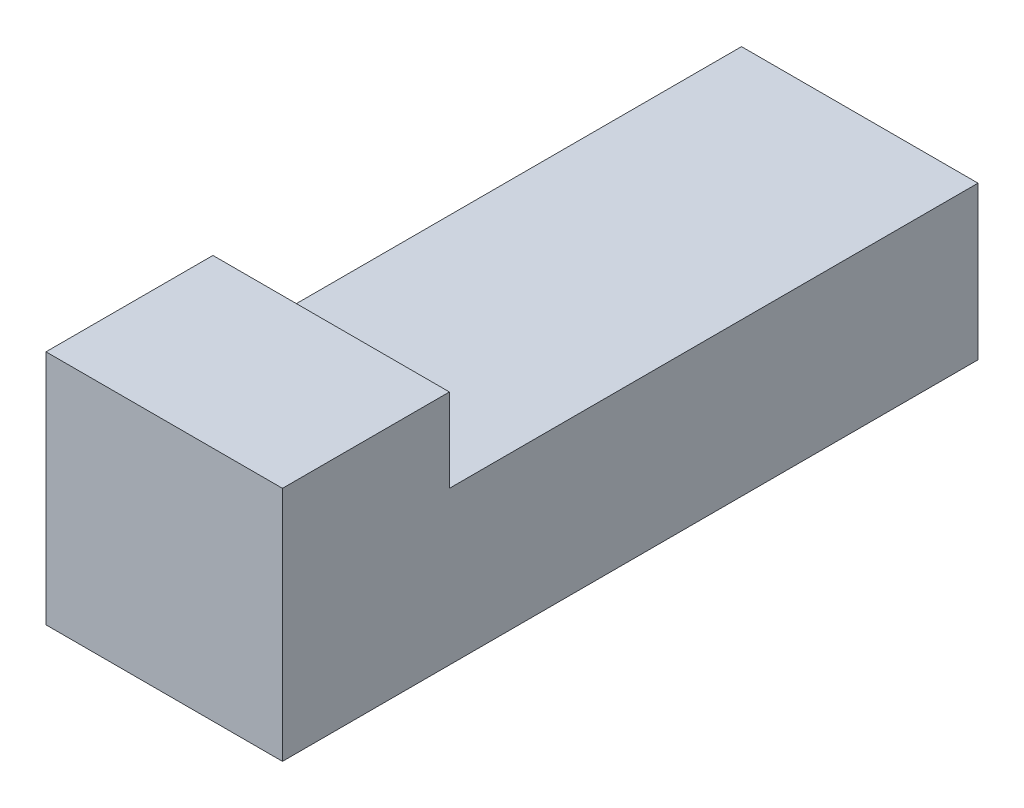
from build123d import *

# Parameters (mm, degrees)
SKETCH1_W           = 4.318
SKETCH1_H           = 4.318
BOSS_EXTRUDE1_DEPTH = 12.7
SKETCH2_W           = 4.318
SKETCH2_H           = 1.524
CUT_EXTRUDE1_DEPTH  = 12.7


with BuildPart() as part:
    # Sketch1 → Boss-Extrude1 (new body)
    with BuildSketch(Plane.XY):
        with Locations((-32.122041713, -0.776020695)):
            Rectangle(SKETCH1_W, SKETCH1_H)
    extrude(amount=BOSS_EXTRUDE1_DEPTH)

    # Sketch2 → Cut-Extrude1 (cut)
    with BuildSketch(Plane.XY.offset(9.652)):
        with Locations((-32.122041713, 0.620979305)):
            Rectangle(SKETCH2_W, SKETCH2_H)
    extrude(amount=-CUT_EXTRUDE1_DEPTH, mode=Mode.SUBTRACT)


solid = part.part
